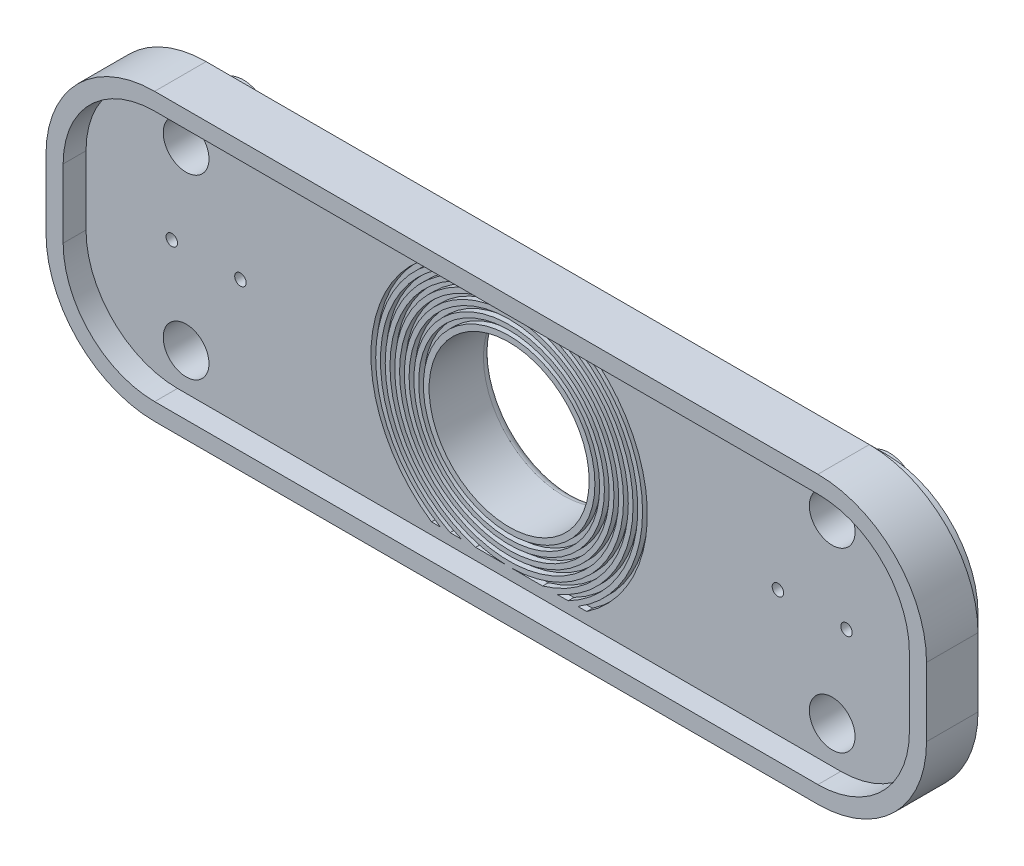
from build123d import *

# Parameters (mm, degrees)
BOSS_EXTRUDE1_DEPTH      = 1
BOSS_EXTRUDE2_DEPTH      = 3
BOSS_EXTRUDE2_DEPTH_BACK = 1.5
BOSS_EXTRUDE3_DEPTH      = 2
SKETCH3_R                = 7
SKETCH3_R_2              = 2
SKETCH3_R_3              = 0.5
CUT_EXTRUDE1_DEPTH       = 41.675545479
SKETCH4_R                = 8.5
SKETCH4_R_2              = 7
BOSS_EXTRUDE4_DEPTH      = 3.5
SKETCH5_R                = 4.25
SKETCH5_R_2              = 3.1
BOSS_EXTRUDE5_DEPTH      = 3.9
SKETCH6_R                = 2.5
SKETCH6_R_2              = 1.6
BOSS_EXTRUDE6_DEPTH      = 4.5
SKETCH7_R                = 2.5
SKETCH7_R_2              = 2
BOSS_EXTRUDE7_DEPTH      = 3
FILLET1_R                = 0.75
CHAMFER1_SIZE            = 0.75
CHAMFER2_SIZE            = 0.6
SKETCH8_R                = 9.583333337
SKETCH8_R_2              = 9.16666667
SKETCH8_R_3              = 8.750000003
SKETCH8_R_4              = 8.333333337
SKETCH8_R_5              = 7.91666667
SKETCH8_R_6              = 7.5
CUT_EXTRUDE6_DEPTH       = 0.5


with BuildPart() as part:
    # Sketch1 → Boss-Extrude1 (new, symmetric)
    with BuildSketch(Plane.XY):
        with BuildLine():
            Line((-29, 11), (29, 11))
            ThreePointArc((29, 11), (34.656854249, 8.656854249), (37, 3))
            Line((37, 3), (37, -3))
            ThreePointArc((37, -3), (34.656854249, -8.656854249), (29, -11))
            Line((29, -11), (-29, -11))
            ThreePointArc((-29, -11), (-34.656854249, -8.656854249), (-37, -3))
            Line((-37, -3), (-37, 3))
            ThreePointArc((-37, 3), (-34.656854249, 8.656854249), (-29, 11))
        make_face()
    extrude(amount=BOSS_EXTRUDE1_DEPTH, both=True)

    # Sketch1_4 → Boss-Extrude2 (add, two sides)
    with BuildSketch(Plane.XY) as boss_extrude2_sk:
        with BuildLine():
            Line((-29, 12.5), (29, 12.5))
            ThreePointArc((29, 12.5), (35.717514421, 9.717514421), (38.5, 3))
            Line((38.5, 3), (38.5, -3))
            ThreePointArc((38.5, -3), (35.717514421, -9.717514421), (29, -12.5))
            Line((29, -12.5), (-29, -12.5))
            ThreePointArc((-29, -12.5), (-35.717514421, -9.717514421), (-38.5, -3))
            Line((-38.5, -3), (-38.5, 3))
            ThreePointArc((-38.5, 3), (-35.717514421, 9.717514421), (-29, 12.5))
        make_face()
        with BuildLine():
            Line((-29, 11), (29, 11))
            ThreePointArc((29, 11), (34.656854249, 8.656854249), (37, 3))
            Line((37, 3), (37, -3))
            ThreePointArc((37, -3), (34.656854249, -8.656854249), (29, -11))
            Line((29, -11), (-29, -11))
            ThreePointArc((-29, -11), (-34.656854249, -8.656854249), (-37, -3))
            Line((-37, -3), (-37, 3))
            ThreePointArc((-37, 3), (-34.656854249, 8.656854249), (-29, 11))
        make_face(mode=Mode.SUBTRACT)
    extrude(amount=BOSS_EXTRUDE2_DEPTH)
    extrude(boss_extrude2_sk.sketch, amount=-BOSS_EXTRUDE2_DEPTH_BACK)

    # Sketch2 → Boss-Extrude3 (add)
    with BuildSketch(Plane(origin=(0, 0, -1), x_dir=(-1, 0, 0), z_dir=(0, 0, -1))):
        with BuildLine():
            Line((29, 11), (-29, 11))
            ThreePointArc((-29, 11), (-34.656854249, 8.656854249), (-37, 3))
            Line((-37, 3), (-37, -3))
            ThreePointArc((-37, -3), (-34.656854249, -8.656854249), (-29, -11))
            Line((-29, -11), (29, -11))
            ThreePointArc((29, -11), (34.656854249, -8.656854249), (37, -3))
            Line((37, -3), (37, 3))
            ThreePointArc((37, 3), (34.656854249, 8.656854249), (29, 11))
        make_face()
        with BuildLine():
            Line((29, 10), (-29, 10))
            ThreePointArc((-29, 10), (-33.949747468, 7.949747468), (-36, 3))
            Line((-36, 3), (-36, -3))
            ThreePointArc((-36, -3), (-33.949747468, -7.949747468), (-29, -10))
            Line((-29, -10), (29, -10))
            ThreePointArc((29, -10), (33.949747468, -7.949747468), (36, -3))
            Line((36, -3), (36, 3))
            ThreePointArc((36, 3), (33.949747468, 7.949747468), (29, 10))
        make_face(mode=Mode.SUBTRACT)
    extrude(amount=BOSS_EXTRUDE3_DEPTH)

    # Sketch3 → Cut-Extrude1 (cut, through all)
    with BuildSketch(Plane.XY.offset(1)):
        Circle(SKETCH3_R)
        with Locations((-28.25, 7.75)):
            Circle(SKETCH3_R_2)
        with Locations((28.25, 7.75)):
            Circle(SKETCH3_R_2)
        with Locations((28.25, -7.75)):
            Circle(SKETCH3_R_2)
        with Locations((-28.25, -7.75)):
            Circle(SKETCH3_R_2)
        with Locations((-29.5, 0)):
            Circle(SKETCH3_R_3)
        with Locations((29.5, 0)):
            Circle(SKETCH3_R_3)
        with Locations((23.5, 0)):
            Circle(SKETCH3_R_3)
        with Locations((-23.5, 0)):
            Circle(SKETCH3_R_3)
    extrude(amount=-CUT_EXTRUDE1_DEPTH, mode=Mode.SUBTRACT)

    # Sketch4 → Boss-Extrude4 (add)
    with BuildSketch(Plane(origin=(0, 0, -1), x_dir=(-1, 0, 0), z_dir=(0, 0, -1))):
        with Locations(Location((0, 0, 0), (0, 0, 180))):
            Circle(SKETCH4_R)
        with Locations(Location((0, 0, 0), (0, 0, 180))):
            Circle(SKETCH4_R_2, mode=Mode.SUBTRACT)
    extrude(amount=BOSS_EXTRUDE4_DEPTH)

    # Sketch5 → Boss-Extrude5 (add)
    with BuildSketch(Plane(origin=(0, 0, -1), x_dir=(-1, 0, 0), z_dir=(0, 0, -1))):
        with Locations(Location((29.5, 0, 0), (0, 0, 180))):
            Circle(SKETCH5_R)
        with Locations((29.5, 0)):
            Circle(SKETCH5_R_2, mode=Mode.SUBTRACT)
        with Locations(Location((-29.5, 0, 0), (0, 0, 180))):
            Circle(SKETCH5_R)
        with Locations((-29.5, 0)):
            Circle(SKETCH5_R_2, mode=Mode.SUBTRACT)
    extrude(amount=BOSS_EXTRUDE5_DEPTH)

    # Sketch6 → Boss-Extrude6 (add)
    with BuildSketch(Plane(origin=(0, 0, -1), x_dir=(-1, 0, 0), z_dir=(0, 0, -1))):
        with Locations(Location((23.5, 0, 0), (0, 0, 323.731147776))):
            Circle(SKETCH6_R)
        with Locations((23.5, 0)):
            Circle(SKETCH6_R_2, mode=Mode.SUBTRACT)
        with Locations(Location((-23.5, 0, 0), (0, 0, 216.268852224))):
            Circle(SKETCH6_R)
        with Locations((-23.5, 0)):
            Circle(SKETCH6_R_2, mode=Mode.SUBTRACT)
    extrude(amount=BOSS_EXTRUDE6_DEPTH)

    # Sketch7 → Boss-Extrude7 (add)
    with BuildSketch(Plane(origin=(0, 0, -1), x_dir=(-1, 0, 0), z_dir=(0, 0, -1))):
        with Locations(Location((-28.25, 7.75, 0), (0, 0, 116.320774831))):
            Circle(SKETCH7_R)
        with Locations(Location((-28.25, 7.75, 0), (0, 0, 180))):
            Circle(SKETCH7_R_2, mode=Mode.SUBTRACT)
        with Locations(Location((-28.25, -7.75, 0), (0, 0, 243.679225169))):
            Circle(SKETCH7_R)
        with Locations(Location((-28.25, -7.75, 0), (0, 0, 180))):
            Circle(SKETCH7_R_2, mode=Mode.SUBTRACT)
        with Locations(Location((28.25, 7.75, 0), (0, 0, 115.841932763))):
            Circle(SKETCH7_R)
        with Locations(Location((28.25, 7.75, 0), (0, 0, 180))):
            Circle(SKETCH7_R_2, mode=Mode.SUBTRACT)
        with Locations(Location((28.25, -7.75, 0), (0, 0, 244.158067237))):
            Circle(SKETCH7_R)
        with Locations(Location((28.25, -7.75, 0), (0, 0, 180))):
            Circle(SKETCH7_R_2, mode=Mode.SUBTRACT)
    extrude(amount=BOSS_EXTRUDE7_DEPTH)

    # Fillet1
    fillet1_edges = [part.edges().sort_by_distance(p)[0] for p in [
        (-7, 0, -4.5),
    ]]
    fillet(fillet1_edges, radius=FILLET1_R)

    # Chamfer1
    chamfer1_edges = [part.edges().sort_by_distance(p)[0] for p in [
        (-24, 0, -1),
        (23, 0, -1),
        (29, 0, -1),
        (-30, 0, -1),
    ]]
    chamfer(chamfer1_edges, length=CHAMFER1_SIZE)

    # Chamfer2
    chamfer2_edges = [part.edges().sort_by_distance(p)[0] for p in [
        (-21.9, 0, -5.5),
        (25.1, 0, -5.5),
    ]]
    chamfer(chamfer2_edges, length=CHAMFER2_SIZE)

    # Sketch8 → Cut-Extrude6 (cut)
    with BuildSketch(Plane.XY.offset(1)):
        Circle(SKETCH8_R)
        Circle(SKETCH8_R_2, mode=Mode.SUBTRACT)
        Circle(SKETCH8_R_3)
        Circle(SKETCH8_R_4, mode=Mode.SUBTRACT)
        Circle(SKETCH8_R_5)
        Circle(SKETCH8_R_6, mode=Mode.SUBTRACT)
        with BuildLine():
            Line((-0.258220535, 10), (-2.928549141, 10))
            ThreePointArc((-2.928549141, 10), (-10.420000003, 0), (-2.928549141, -10))
            Line((-2.928549141, -10), (-0.258220535, -10))
            ThreePointArc((-0.258220535, -10), (-10.003333337, 0), (-0.258220535, 10))
        make_face()
        with BuildLine():
            Line((-4.175325678, 10), (-5.161154056, 10))
            ThreePointArc((-5.161154056, 10), (-11.253333337, 0), (-5.161154056, -10))
            Line((-5.161154056, -10), (-4.175325678, -10))
            ThreePointArc((-4.175325678, -10), (-10.83666667, 0), (-4.175325678, 10))
        make_face()
        with BuildLine():
            Line((-6.015721077, 10), (-6.788778328, 10))
            ThreePointArc((-6.788778328, 10), (-12.08666667, 0), (-6.788778328, -10))
            Line((-6.788778328, -10), (-6.015721077, -10))
            ThreePointArc((-6.015721077, -10), (-11.670000003, 0), (-6.015721077, 10))
        make_face()
        with BuildLine():
            Line((2.928549141, 10), (0.258220535, 10))
            ThreePointArc((0.258220535, 10), (7.164137908, 6.981533204), (10.003333337, 0))
            ThreePointArc((10.003333337, 0), (7.164137908, -6.981533204), (0.258220535, -10))
            Line((0.258220535, -10), (2.928549141, -10))
            ThreePointArc((2.928549141, -10), (10.420000003, 0), (2.928549141, 10))
        make_face()
        with BuildLine():
            Line((5.161154056, 10), (4.175325678, 10))
            ThreePointArc((4.175325678, 10), (10.83666667, 0), (4.175325678, -10))
            Line((4.175325678, -10), (5.161154056, -10))
            ThreePointArc((5.161154056, -10), (11.253333337, 0), (5.161154056, 10))
        make_face()
        with BuildLine():
            Line((6.788778328, 10), (6.015721077, 10))
            ThreePointArc((6.015721077, 10), (11.670000003, 0), (6.015721077, -10))
            Line((6.015721077, -10), (6.788778328, -10))
            ThreePointArc((6.788778328, -10), (12.08666667, 0), (6.788778328, 10))
        make_face()
    extrude(amount=-CUT_EXTRUDE6_DEPTH, mode=Mode.SUBTRACT)


solid = part.part
